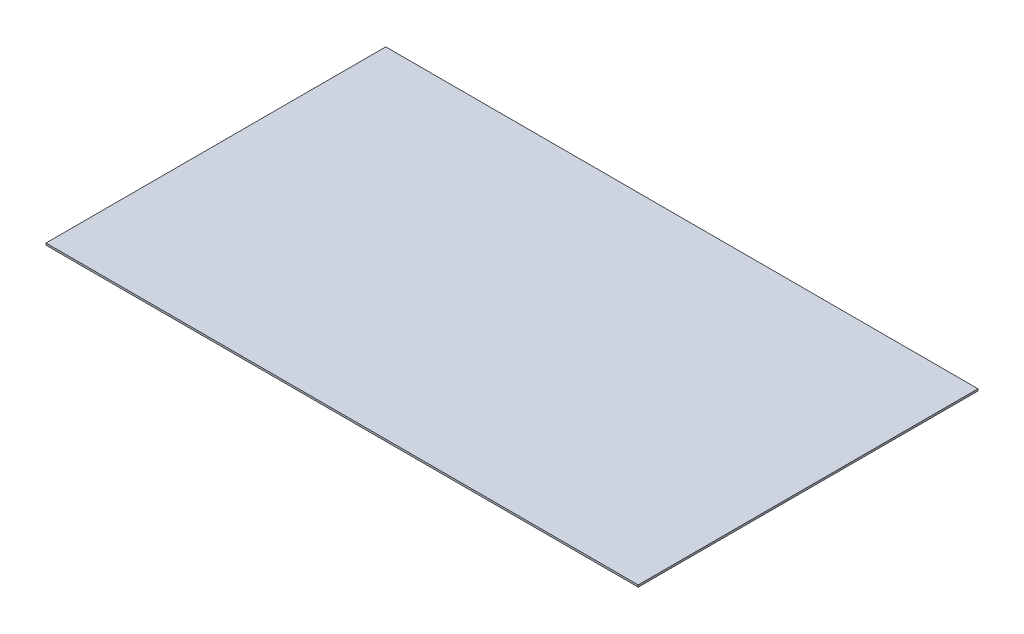
from build123d import *

# Parameters (mm, degrees)
SKETCH1_W           = 69.725
SKETCH1_H           = 40
BOSS_EXTRUDE1_DEPTH = 0.1125


with BuildPart() as part:
    # Sketch1 → Boss-Extrude1 (new body, symmetric)
    with BuildSketch(Plane(origin=(0, 0, 0), x_dir=(1, 0, 0), z_dir=(0, 1, 0))):
        Rectangle(SKETCH1_W, SKETCH1_H)
    extrude(amount=BOSS_EXTRUDE1_DEPTH, both=True)


solid = part.part
